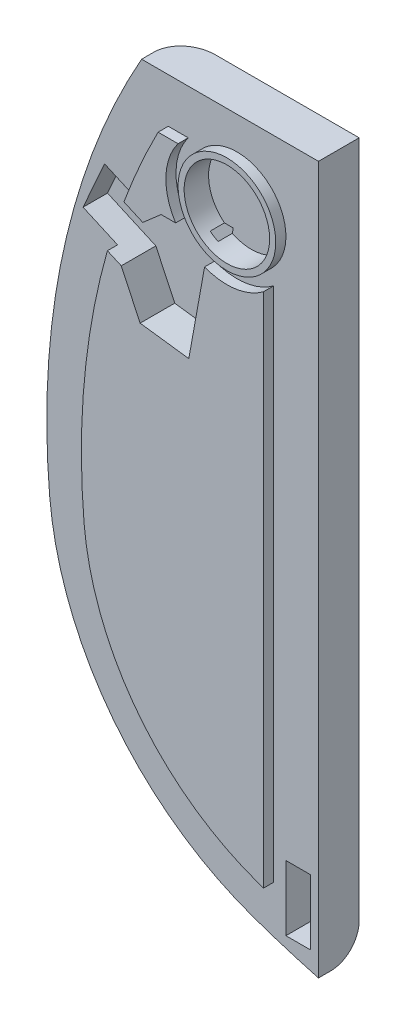
from build123d import *

# Parameters (mm, degrees)
BOSS_EXTRUDE1_DEPTH = 10
FILLET1_R           = 7
CUT_EXTRUDE5_DEPTH  = 6
BOSS_EXTRUDE2_DEPTH = 2.5
SKETCH10_R          = 12
BOSS_EXTRUDE3_DEPTH = 2.5
SKETCH11_R          = 10.5
CUT_EXTRUDE6_DEPTH  = 6
SKETCH12_W          = 6
SKETCH12_H          = 16
CUT_EXTRUDE7_DEPTH  = 6


with BuildPart() as part:
    # Sketch1 → Boss-Extrude1 (new body)
    with BuildSketch(Plane.XY):
        with BuildLine():
            Line((0, 0), (-43.45, 0))
            ThreePointArc((-43.45, 0), (-62.674676093, -50.388720896), (-66.045303679, -104.214831977))
            ThreePointArc((-66.045303679, -104.214831977), (-50.462862729, -143.891349815), (-15.893438709, -168.83114646))
            ThreePointArc((-15.893438709, -168.83114646), (-7.994010798, -171.448872708), (0, -173.76171585))
            Line((0, -173.76171585), (0, 0))
        make_face()
    extrude(amount=BOSS_EXTRUDE1_DEPTH)

    # Fillet1
    fillet1_edges = [part.edges().sort_by_distance(p)[0] for p in [
        (-7.994010798, -171.448872708, 0),
        (-50.462862729, -143.891349815, 0),
        (-62.674676093, -50.388720896, 0),
    ]]
    fillet(fillet1_edges, radius=FILLET1_R)

    # Sketch7 → Cut-Extrude5 (cut)
    with BuildSketch(Plane.XY.offset(10)):
        Polygon((-55.192518946, -32.743925992), (-52.550619838, -26.805039808), (-40.67284747, -32.088838025), (-36.166399237, -28.159530493), (-24.434809325, -28.159530493), (-29.358040317, -55.413615039), (-41.316202905, -53.845312659), (-45.956645687, -43.966610392), (-57.834418054, -38.682812175), align=None)
    extrude(amount=-CUT_EXTRUDE5_DEPTH, mode=Mode.SUBTRACT)

    # Sketch9 → Boss-Extrude2 (add)
    with BuildSketch(Plane.XY.offset(10)):
        with BuildLine():
            Line((-11, -158.888662803), (-11, -32))
            ThreePointArc((-11, -32), (-17.986369061, -34.864228552), (-25.482975715, -33.961983287))
            Line((-25.482975715, -33.961983287), (-29.358040317, -55.413615039))
            Line((-29.358040317, -55.413615039), (-41.316202905, -53.845312659))
            Line((-41.316202905, -53.845312659), (-45.956645687, -43.966610392))
            Line((-45.956645687, -43.966610392), (-49.358199776, -42.453437309))
            ThreePointArc((-49.358199776, -42.453437309), (-55.003200537, -72.586352384), (-55.088286823, -103.243347748))
            ThreePointArc((-55.088286823, -103.243347748), (-41.773132254, -137.146827277), (-12.233650883, -158.457817531))
            ThreePointArc((-12.233650883, -158.457817531), (-11.617167152, -158.674218597), (-11, -158.888662803))
        make_face()
        with BuildLine():
            Line((-32, -11), (-36.901831421, -11))
            ThreePointArc((-36.901831421, -11), (-41.398196048, -20.383917403), (-45.30604713, -30.027770398))
            Line((-45.30604713, -30.027770398), (-40.67284747, -32.088838025))
            Line((-40.67284747, -32.088838025), (-36.166399237, -28.159530493))
            Line((-36.166399237, -28.159530493), (-32.586582623, -28.159530493))
            ThreePointArc((-32.586582623, -28.159530493), (-34.991243543, -19.487538254), (-32, -11))
        make_face()
    extrude(amount=BOSS_EXTRUDE2_DEPTH)

    # Sketch10 → Boss-Extrude3 (add)
    with BuildSketch(Plane.XY.offset(10)):
        with Locations((-20, -20)):
            Circle(SKETCH10_R)
    extrude(amount=BOSS_EXTRUDE3_DEPTH)

    # Sketch11 → Cut-Extrude6 (cut)
    with BuildSketch(Plane.XY.offset(12.5)):
        with Locations((-20, -20)):
            Circle(SKETCH11_R)
    extrude(amount=-CUT_EXTRUDE6_DEPTH, mode=Mode.SUBTRACT)

    # Sketch12 → Cut-Extrude7 (cut)
    with BuildSketch(Plane.XY.offset(10)):
        with Locations((-5, -160.76171585)):
            Rectangle(SKETCH12_W, SKETCH12_H)
    extrude(amount=-CUT_EXTRUDE7_DEPTH, mode=Mode.SUBTRACT)


solid = part.part
